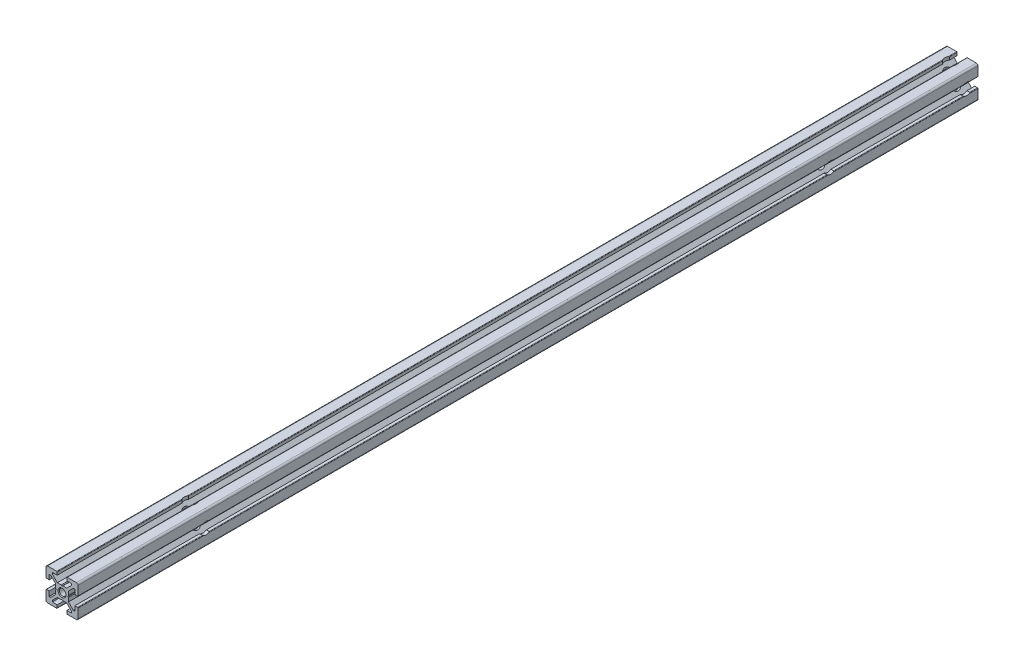
from build123d import *

# Parameters (mm, degrees)
BOSS_EXTRUDE1_DEPTH     = 562
SKETCH3_R               = 3.675
CUT_EXTRUDE1_DEPTH      = 10
CUT_EXTRUDE1_DEPTH_BACK = 10
SKETCH4_R               = 3.675
CUT_EXTRUDE2_DEPTH      = 10
CUT_EXTRUDE2_DEPTH_BACK = 10
SKETCH5_R               = 3.6751
CUT_EXTRUDE3_DEPTH      = 10
CUT_EXTRUDE3_DEPTH_BACK = 10
SKETCH6_R               = 3.6752
CUT_EXTRUDE4_DEPTH      = 10
CUT_EXTRUDE4_DEPTH_BACK = 10
SKETCH7_R               = 3.6752
CUT_EXTRUDE5_DEPTH      = 10
CUT_EXTRUDE5_DEPTH_BACK = 10


with BuildPart() as part:
    # Sketch1 → Boss-Extrude1 (new body)
    with BuildSketch(Plane.XY):
        with BuildLine():
            Line((-10, 9), (-10, 3.29999995))
            ThreePointArc((-10, 3.29999995), (-9.912132049, 3.087867916), (-9.7, 3))
            Line((-9.7, 3), (-8, 3))
            Line((-8, 3), (-8, 6))
            Line((-8, 6), (-7.060677, 6))
            Line((-7.060677, 6), (-4, 2.93932965))
            Line((-4, 2.93932965), (-4, 0.519615242))
            Line((-4, 0.519615242), (-3.699996283, -6.437e-06))
            Line((-3.699996283, -6.437e-06), (-4, -0.519628117))
            Line((-4, -0.519628117), (-4, -2.93933725))
            Line((-4, -2.93933725), (-7.0606695, -6))
            Line((-7.0606695, -6), (-8, -6))
            Line((-8, -6), (-8, -3))
            Line((-8, -3), (-9.7, -3))
            ThreePointArc((-9.7, -3), (-9.912132049, -3.087867916), (-10, -3.29999995))
            Line((-10, -3.29999995), (-10, -9))
            ThreePointArc((-10, -9), (-9.707106781, -9.707106781), (-9, -10))
            Line((-9, -10), (-3.29999995, -10))
            ThreePointArc((-3.29999995, -10), (-3.087867916, -9.912132049), (-3, -9.7))
            Line((-3, -9.7), (-3, -8))
            Line((-3, -8), (-6, -8))
            Line((-6, -8), (-6, -7.0606515))
            Line((-6, -7.0606515), (-2.9393489, -4))
            Line((-2.9393489, -4), (-0.519615242, -4))
            Line((-0.519615242, -4), (6.437e-06, -3.699996283))
            Line((6.437e-06, -3.699996283), (0.519628117, -4))
            Line((0.519628117, -4), (2.9393227, -4))
            Line((2.9393227, -4), (6, -7.060677))
            Line((6, -7.060677), (6, -8))
            Line((6, -8), (3, -8))
            Line((3, -8), (3, -9.7))
            ThreePointArc((3, -9.7), (3.087867916, -9.912132049), (3.29999995, -10))
            Line((3.29999995, -10), (9, -10))
            ThreePointArc((9, -10), (9.707106781, -9.707106781), (10, -9))
            Line((10, -9), (10, -3.29999995))
            ThreePointArc((10, -3.29999995), (9.912132049, -3.087867916), (9.7, -3))
            Line((9.7, -3), (8, -3))
            Line((8, -3), (8, -6))
            Line((8, -6), (7.0606435, -6))
            Line((7.0606435, -6), (4, -2.9393482))
            Line((4, -2.9393482), (4, -0.519615242))
            Line((4, -0.519615242), (3.699996283, 6.437e-06))
            Line((3.699996283, 6.437e-06), (4, 0.519628117))
            Line((4, 0.519628117), (4, 2.9393401))
            Line((4, 2.9393401), (7.060651, 6))
            Line((7.060651, 6), (8, 6))
            Line((8, 6), (8, 3))
            Line((8, 3), (9.7, 3))
            ThreePointArc((9.7, 3), (9.912132049, 3.087867916), (10, 3.29999995))
            Line((10, 3.29999995), (10, 9))
            ThreePointArc((10, 9), (9.707106781, 9.707106781), (9, 10))
            Line((9, 10), (3.29999995, 10))
            ThreePointArc((3.29999995, 10), (3.087867916, 9.912132049), (3, 9.7))
            Line((3, 9.7), (3, 8))
            Line((3, 8), (6, 8))
            Line((6, 8), (6, 7.060669))
            Line((6, 7.060669), (2.9393308, 4))
            Line((2.9393308, 4), (0.519615242, 4))
            Line((0.519615242, 4), (-6.437e-06, 3.699996283))
            Line((-6.437e-06, 3.699996283), (-0.519628117, 4))
            Line((-0.519628117, 4), (-2.93935655, 4))
            Line((-2.93935655, 4), (-6, 7.0606435))
            Line((-6, 7.0606435), (-6, 8))
            Line((-6, 8), (-3, 8))
            Line((-3, 8), (-3, 9.7))
            ThreePointArc((-3, 9.7), (-3.087867966, 9.912132034), (-3.3, 10))
            Line((-3.3, 10), (-9, 10))
            ThreePointArc((-9, 10), (-9.707106781, 9.707106781), (-10, 9))
        make_face()
    extrude(amount=-BOSS_EXTRUDE1_DEPTH)

    # Sketch2 → Cut-Revolve1 (revolve, cut)
    with BuildSketch(Plane(origin=(0, 0, 0), x_dir=(0, 0, -1), z_dir=(1, 0, 0))):
        Polygon((0, 0), (0, 2.5), (0.433, 2.067), (562, 2.067), (562, 0), align=None)
    revolve(axis=Axis((0, 0, -562), (0, 0, 1)), mode=Mode.SUBTRACT)

    # Sketch3 → Cut-Extrude1 (cut, two sides)
    with BuildSketch(Plane(origin=(0, 0, 0), x_dir=(0, 0, -1), z_dir=(1, 0, 0))) as cut_extrude1_sk:
        with Locations((555, 6.437e-06)):
            Circle(SKETCH3_R)
    extrude(amount=CUT_EXTRUDE1_DEPTH, mode=Mode.SUBTRACT)
    extrude(cut_extrude1_sk.sketch, amount=-CUT_EXTRUDE1_DEPTH_BACK, mode=Mode.SUBTRACT)

    # Sketch4 → Cut-Extrude2 (cut, two sides)
    with BuildSketch(Plane(origin=(0, 0, 0), x_dir=(1, 0, 0), z_dir=(0, 1, 0))) as cut_extrude2_sk:
        with Locations((6.437e-06, 555)):
            Circle(SKETCH4_R)
    extrude(amount=CUT_EXTRUDE2_DEPTH, mode=Mode.SUBTRACT)
    extrude(cut_extrude2_sk.sketch, amount=-CUT_EXTRUDE2_DEPTH_BACK, mode=Mode.SUBTRACT)

    # Sketch5 → Cut-Extrude3 (cut, two sides)
    with BuildSketch(Plane(origin=(0, 0, 0), x_dir=(0, 0, -1), z_dir=(1, 0, 0))) as cut_extrude3_sk:
        with Locations((470, 6.437e-06)):
            Circle(SKETCH5_R)
    extrude(amount=CUT_EXTRUDE3_DEPTH, mode=Mode.SUBTRACT)
    extrude(cut_extrude3_sk.sketch, amount=-CUT_EXTRUDE3_DEPTH_BACK, mode=Mode.SUBTRACT)

    # Sketch6 → Cut-Extrude4 (cut, two sides)
    with BuildSketch(Plane(origin=(0, 0, 0), x_dir=(0, 0, -1), z_dir=(1, 0, 0))) as cut_extrude4_sk:
        with Locations((80, 6.437e-06)):
            Circle(SKETCH6_R)
    extrude(amount=CUT_EXTRUDE4_DEPTH, mode=Mode.SUBTRACT)
    extrude(cut_extrude4_sk.sketch, amount=-CUT_EXTRUDE4_DEPTH_BACK, mode=Mode.SUBTRACT)

    # Sketch7 → Cut-Extrude5 (cut, two sides)
    with BuildSketch(Plane(origin=(0, 0, 0), x_dir=(1, 0, 0), z_dir=(0, 1, 0))) as cut_extrude5_sk:
        with Locations((-6.437e-06, 80)):
            Circle(SKETCH7_R)
    extrude(amount=CUT_EXTRUDE5_DEPTH, mode=Mode.SUBTRACT)
    extrude(cut_extrude5_sk.sketch, amount=-CUT_EXTRUDE5_DEPTH_BACK, mode=Mode.SUBTRACT)


solid = part.part
